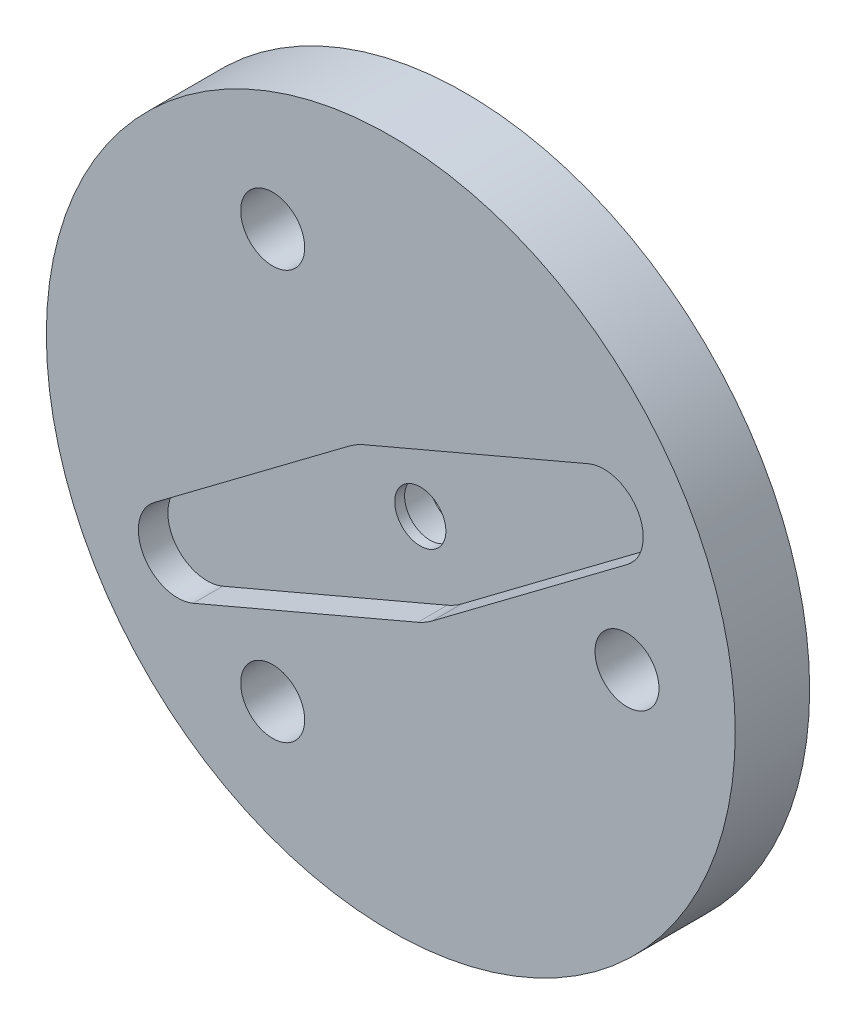
from build123d import *

# Parameters (mm, degrees)
SCHIZZO1_R                   = 17.5
ESTRUSIONE_ESTRUSIONE1_DEPTH = 3.781092502
SCHIZZO2_R                   = 1.625
SCHIZZO2_R_2                 = 1.3
TAGLIO_ESTRUSIONE1_DEPTH     = 4.781092502
CUT_EXTRUDE1_DEPTH           = 1.5
SCHIZZO4_R                   = 2
TAGLIO_ESTRUSIONE2_DEPTH     = 1.781093


with BuildPart() as part:
    # Schizzo1 → Estrusione-Estrusione1 (new body)
    with BuildSketch(Plane.XY):
        Circle(SCHIZZO1_R)
    extrude(amount=ESTRUSIONE_ESTRUSIONE1_DEPTH)

    # Schizzo2 → Taglio-Estrusione1 (cut, through all)
    with BuildSketch(Plane.XY.offset(3.781092502)):
        with Locations((12, 0)):
            Circle(SCHIZZO2_R)
        with Locations((-6, 10.392304845)):
            Circle(SCHIZZO2_R)
        with Locations((-6, -10.392304845)):
            Circle(SCHIZZO2_R)
        Circle(SCHIZZO2_R_2)
    extrude(amount=-TAGLIO_ESTRUSIONE1_DEPTH, mode=Mode.SUBTRACT)

    # Sketch1 → Cut-Extrude1 (cut)
    with BuildSketch(Plane.XY.offset(3.781092502)):
        with BuildLine():
            Line((2.10108498, -2.799185936), (12.025937536, 4.650465179))
            ThreePointArc((12.025937536, 4.650465179), (12.557368355, 7.25), (10.040389753, 8.089534821))
            Line((10.040389753, 8.089534821), (-1.373623641, 3.219185936))
            ThreePointArc((-1.373623641, 3.219185936), (-1.75, 3.031088913), (-2.10108498, 2.799185936))
            Line((-2.10108498, 2.799185936), (-12.025937536, -4.650465179))
            ThreePointArc((-12.025937536, -4.650465179), (-12.557368355, -7.25), (-10.040389753, -8.089534821))
            Line((-10.040389753, -8.089534821), (1.373623641, -3.219185936))
            ThreePointArc((1.373623641, -3.219185936), (1.75, -3.031088913), (2.10108498, -2.799185936))
        make_face()
    extrude(amount=-CUT_EXTRUDE1_DEPTH, mode=Mode.SUBTRACT)

    # Schizzo4 → Taglio-Estrusione2 (cut)
    with BuildSketch(Plane(origin=(0, 0, 0), x_dir=(-1, 0, 0), z_dir=(0, 0, -1))):
        Circle(SCHIZZO4_R)
    extrude(amount=-TAGLIO_ESTRUSIONE2_DEPTH, mode=Mode.SUBTRACT)


solid = part.part
